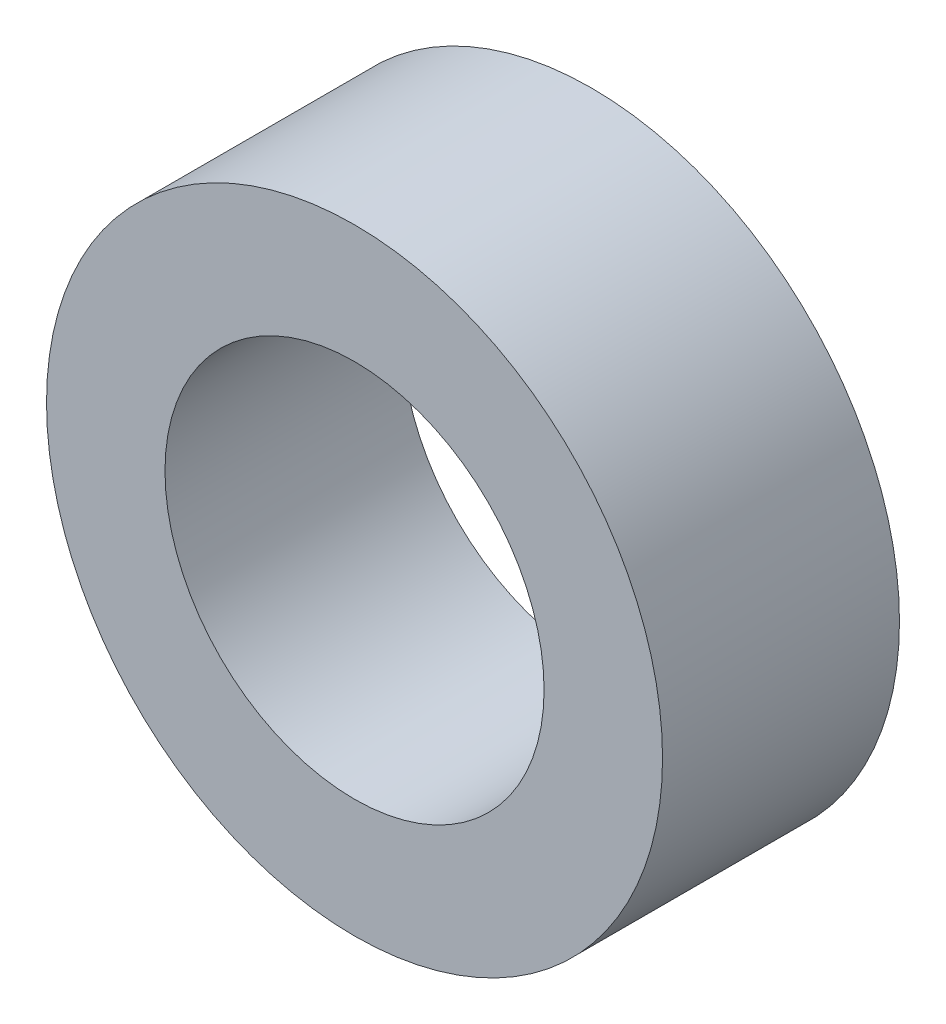
from build123d import *

# Parameters (mm, degrees)
SKETCH1_R           = 6.5
SKETCH1_R_2         = 4
BOSS_EXTRUDE1_DEPTH = 5


with BuildPart() as part:
    # Sketch1 → Boss-Extrude1 (new body)
    with BuildSketch(Plane.XY):
        Circle(SKETCH1_R)
        Circle(SKETCH1_R_2, mode=Mode.SUBTRACT)
    extrude(amount=BOSS_EXTRUDE1_DEPTH)


solid = part.part
